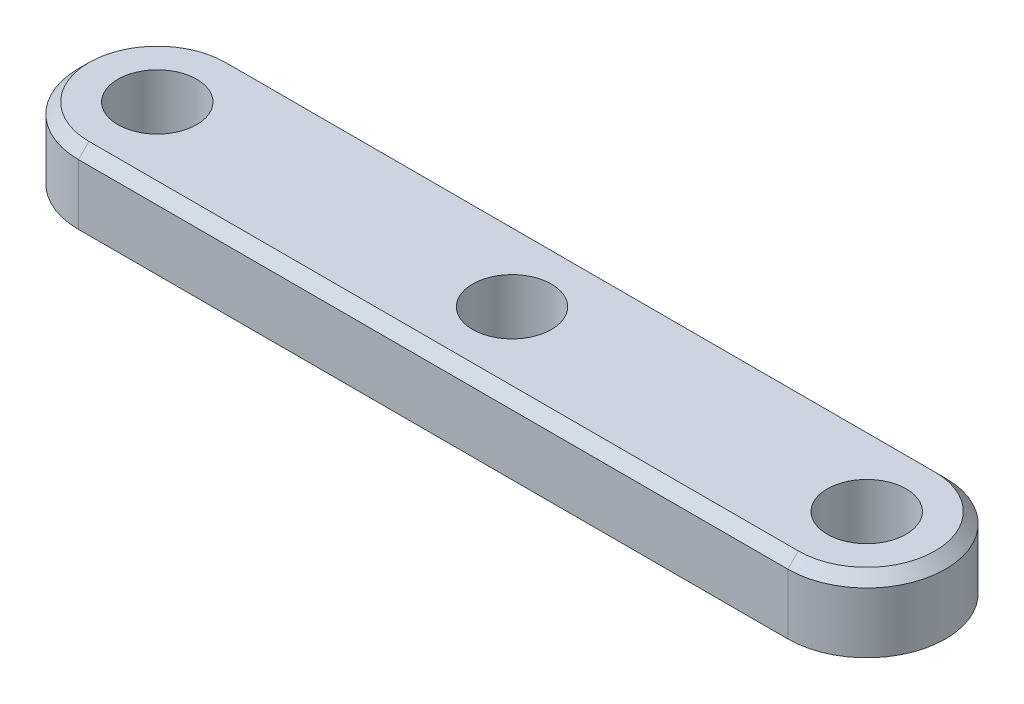
from build123d import *

# Parameters (mm, degrees)
SKETCH1_R           = 1.5
BOSS_EXTRUDE1_DEPTH = 1.35
CHAMFER1_SIZE       = 0.4


with BuildPart() as part:
    # Sketch1 → Boss-Extrude1 (new body, symmetric)
    with BuildSketch(Plane(origin=(0, 0, 0), x_dir=(1, 0, 0), z_dir=(0, 1, 0))):
        with BuildLine():
            Line((-13.5, 3), (13.5, 3))
            ThreePointArc((13.5, 3), (16.5, 0), (13.5, -3))
            Line((13.5, -3), (-13.5, -3))
            ThreePointArc((-13.5, -3), (-16.5, 0), (-13.5, 3))
        make_face()
        with Locations((-13.5, 0)):
            Circle(SKETCH1_R, mode=Mode.SUBTRACT)
        with Locations((13.5, 0)):
            Circle(SKETCH1_R, mode=Mode.SUBTRACT)
        Circle(SKETCH1_R, mode=Mode.SUBTRACT)
    extrude(amount=BOSS_EXTRUDE1_DEPTH, both=True)

    # Chamfer1
    chamfer1_edges = [part.edges().sort_by_distance(p)[0] for p in [
        (16.5, 1.35, 0),
        (0, 1.35, -3),
        (-16.5, 1.35, 0),
        (0, 1.35, 3),
    ]]
    chamfer(chamfer1_edges, length=CHAMFER1_SIZE)


solid = part.part
